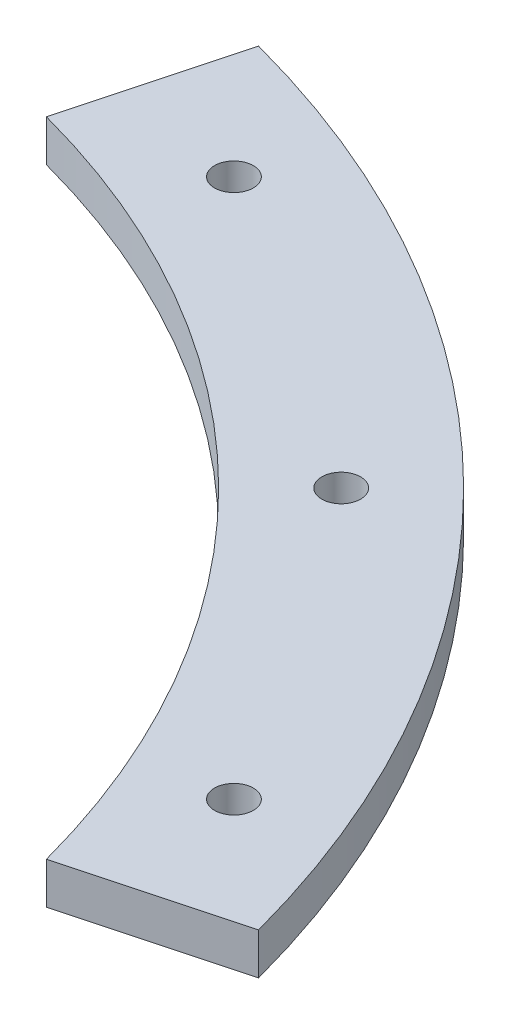
from build123d import *

# Parameters (mm, degrees)
SKETCH1_R           = 1.4224
BOSS_EXTRUDE1_DEPTH = 3.048


with BuildPart() as part:
    # Sketch1 → Boss-Extrude1 (new body)
    with BuildSketch(Plane(origin=(0, 0, 0), x_dir=(1, 0, 0), z_dir=(0, 1, 0))):
        with BuildLine():
            ThreePointArc((76.670362462, 20.543761705), (56.126600757, 56.126600757), (20.543761705, 76.670362462))
            Line((20.543761705, 76.670362462), (17.256759832, 64.403104468))
            ThreePointArc((17.256759832, 64.403104468), (47.146344636, 47.146344636), (64.403104468, 17.256759832))
            Line((64.403104468, 17.256759832), (76.670362462, 20.543761705))
        make_face()
        with Locations((67.466302862, 27.945457648)):
            Circle(SKETCH1_R, mode=Mode.SUBTRACT)
        with Locations((27.945457648, 67.466302862)):
            Circle(SKETCH1_R, mode=Mode.SUBTRACT)
        with Locations((51.636472696, 51.636472696)):
            Circle(SKETCH1_R, mode=Mode.SUBTRACT)
    extrude(amount=BOSS_EXTRUDE1_DEPTH)


solid = part.part
